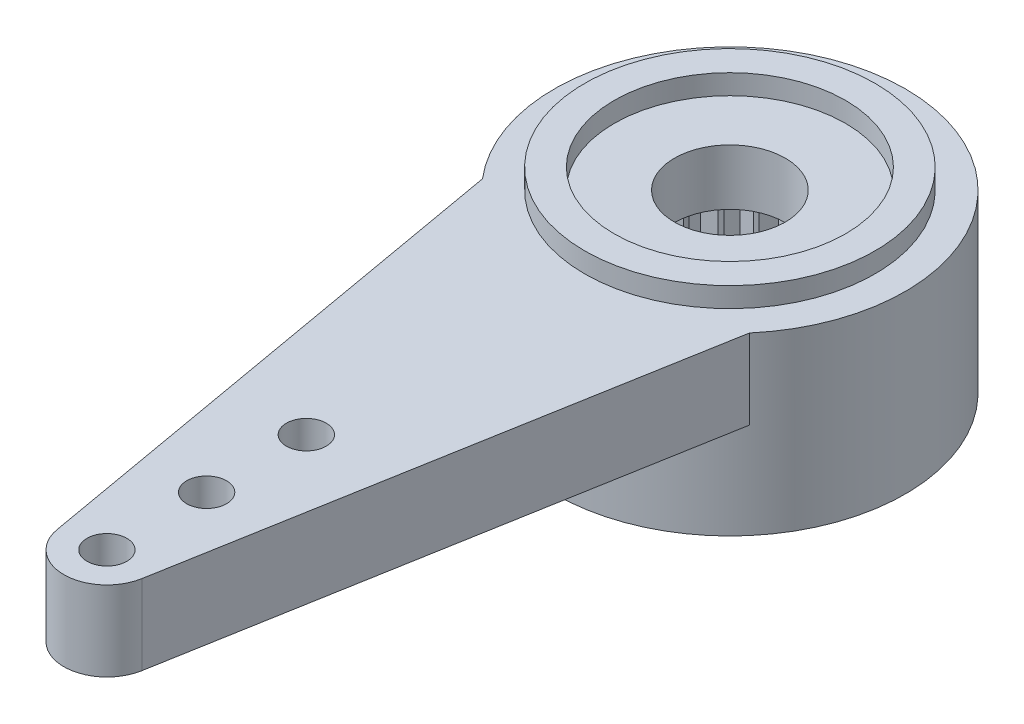
from build123d import *

# Parameters (mm, degrees)
SKETCH1_R               = 4.4
BOSS_EXTRUDE1_DEPTH     = 4.4
BOSS_EXTRUDE2_DEPTH     = 2
SKETCH3_R               = 3.64
SKETCH3_R_2             = 2.9
BOSS_EXTRUDE3_DEPTH     = 0.5
SKETCH4_R               = 1.39
CUT_EXTRUDE1_DEPTH      = 5.4
SKETCH5_R               = 0.5
CUT_EXTRUDE2_DEPTH      = 5.9
LPATTERN1_COUNT         = 3
LPATTERN1_PITCH         = 2.5
MIRROR1_COPY_1_SKETCH_R = 0.5
MIRROR1_COPY_1_DEPTH    = 5.9
MIRROR1_COPY_2_SKETCH_R = 0.5
MIRROR1_COPY_2_DEPTH    = 5.9
CUT_EXTRUDE4_DEPTH      = 3
CIRPATTERN2_COUNT       = 26
SKETCH9_R               = 2.6
CUT_EXTRUDE5_DEPTH      = 3
CUT_EXTRUDE6_DEPTH      = 4.9


with BuildPart() as part:
    # Sketch1 → Boss-Extrude1 (new body)
    with BuildSketch(Plane(origin=(0, 0, 0), x_dir=(1, 0, 0), z_dir=(0, 1, 0))):
        Circle(SKETCH1_R)
    extrude(amount=BOSS_EXTRUDE1_DEPTH)

    # Sketch2 → Boss-Extrude2 (add)
    with BuildSketch(Plane(origin=(0, 4.4, 0), x_dir=(1, 0, 0), z_dir=(0, 1, 0))):
        with BuildLine():
            Line((-1.063592373, 15.807540032), (-3.347342764, 2.855747962))
            ThreePointArc((-3.347342764, 2.855747962), (0, 4.4), (3.347342764, 2.855747962))
            Line((3.347342764, 2.855747962), (1.063592373, 15.807540032))
            ThreePointArc((1.063592373, 15.807540032), (0, 16.7), (-1.063592373, 15.807540032))
        make_face()
    boss_extrude2 = extrude(amount=-BOSS_EXTRUDE2_DEPTH)

    # Sketch3 → Boss-Extrude3 (add)
    with BuildSketch(Plane(origin=(0, 4.4, 0), x_dir=(-1, 0, 0), z_dir=(0, -1, 0))):
        Circle(SKETCH3_R)
        Circle(SKETCH3_R_2, mode=Mode.SUBTRACT)
    extrude(amount=-BOSS_EXTRUDE3_DEPTH)

    # Sketch4 → Cut-Extrude1 (cut, through all)
    with BuildSketch(Plane(origin=(0, 4.4, 0), x_dir=(-1, 0, 0), z_dir=(0, -1, 0))):
        Circle(SKETCH4_R)
    extrude(amount=CUT_EXTRUDE1_DEPTH, mode=Mode.SUBTRACT)

    # Sketch5 → Cut-Extrude2 (cut, through all)
    with BuildSketch(Plane(origin=(0, 0, 0), x_dir=(-1, 0, 0), z_dir=(0, -1, 0))):
        with Locations((0, 15.62)):
            Circle(SKETCH5_R)
    cut_extrude2 = extrude(amount=-CUT_EXTRUDE2_DEPTH, mode=Mode.SUBTRACT)

    # LPattern1: Cut-Extrude2 ×3
    with Locations(*[(0, 0, i * LPATTERN1_PITCH) for i in range(1, LPATTERN1_COUNT)]):
        add(cut_extrude2, mode=Mode.SUBTRACT)

    # Mirror1: Boss-Extrude2, Cut-Extrude2 across plane
    add(boss_extrude2.mirror(Plane.XY))
    add(cut_extrude2.mirror(Plane.XY), mode=Mode.SUBTRACT)

    # Mirror1 copy 1 sketch → Mirror1 copy 1 (cut, through all)
    with BuildSketch(Plane(origin=(0, 0, -2.5), x_dir=(-1, 0, 0), z_dir=(0, -1, 0))):
        with Locations((0, -15.62)):
            Circle(MIRROR1_COPY_1_SKETCH_R)
    extrude(amount=-MIRROR1_COPY_1_DEPTH, mode=Mode.SUBTRACT)

    # Mirror1 copy 2 sketch → Mirror1 copy 2 (cut, through all)
    with BuildSketch(Plane(origin=(0, 0, -5), x_dir=(-1, 0, 0), z_dir=(0, -1, 0))):
        with Locations((0, -15.62)):
            Circle(MIRROR1_COPY_2_SKETCH_R)
    extrude(amount=-MIRROR1_COPY_2_DEPTH, mode=Mode.SUBTRACT)

    # Sketch8 → Cut-Extrude4 (cut)
    with BuildSketch(Plane(origin=(0, 0, 0), x_dir=(-1, 0, 0), z_dir=(0, -1, 0))):
        with BuildLine():
            Line((0, -2.9), (0.262912611, -2.586672952))
            ThreePointArc((0.262912611, -2.586672952), (0, -2.6), (-0.262912611, -2.586672952))
            Line((-0.262912611, -2.586672952), (0, -2.9))
        make_face()
    cut_extrude4 = extrude(amount=-CUT_EXTRUDE4_DEPTH, mode=Mode.SUBTRACT)

    # CirPattern2: Cut-Extrude4 ×26 about axis
    cirpattern2_axis = Axis((0, 0, 0), (0, 1, 0))
    for i in range(1, CIRPATTERN2_COUNT):
        add(cut_extrude4.rotate(cirpattern2_axis, i * 360 / CIRPATTERN2_COUNT), mode=Mode.SUBTRACT)

    # Sketch9 → Cut-Extrude5 (cut)
    with BuildSketch(Plane(origin=(0, 0, 0), x_dir=(-1, 0, 0), z_dir=(0, -1, 0))):
        Circle(SKETCH9_R)
    extrude(amount=-CUT_EXTRUDE5_DEPTH, mode=Mode.SUBTRACT)

    # Horn Trim Sketch → Cut-Extrude6 (cut)
    with BuildSketch(Plane.XZ):
        with BuildLine():
            Line((-4.4, 0), (-4.4, -16.7))
            Line((-4.4, -16.7), (4.4, -16.7))
            Line((4.4, -16.7), (4.4, 0))
            ThreePointArc((4.4, 0), (0, -4.4), (-4.4, 0))
        make_face()
    extrude(amount=-CUT_EXTRUDE6_DEPTH, mode=Mode.SUBTRACT)


solid = part.part
